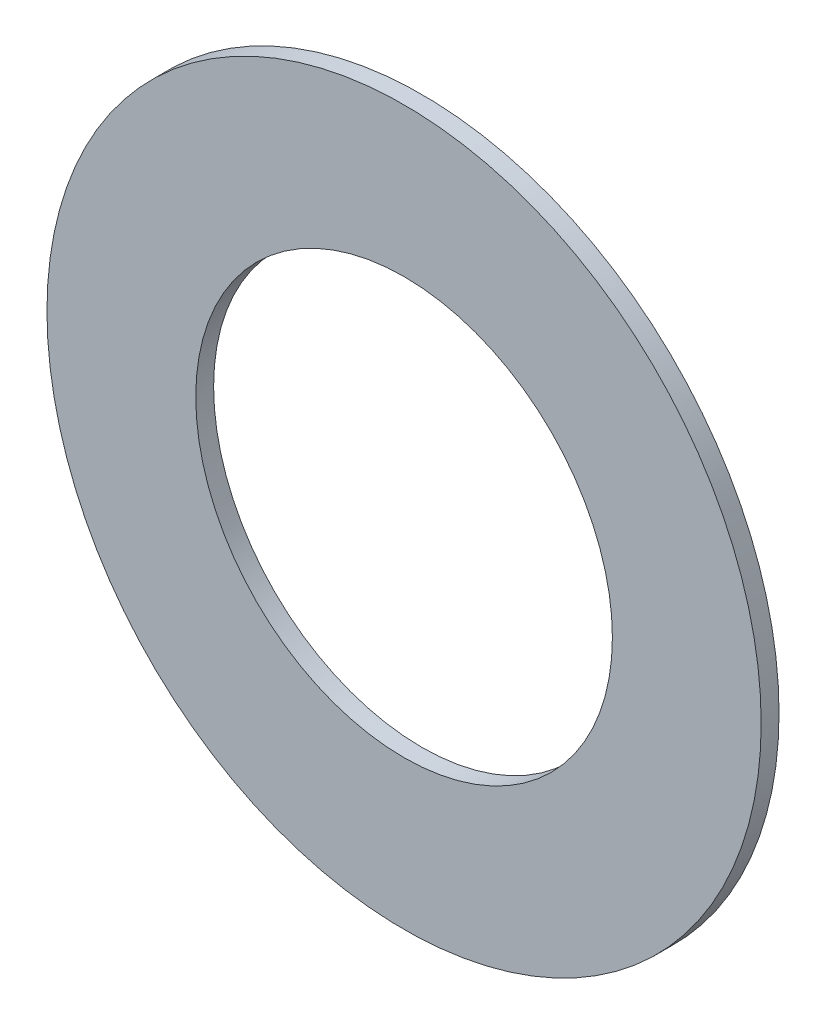
from build123d import *

# Parameters (mm, degrees)
CROQUIS1_R              = 6
CROQUIS1_R_2            = 3.5
SALIENTE_EXTRUIR1_DEPTH = 0.3


with BuildPart() as part:
    # Croquis1 → Saliente-Extruir1 (new body)
    with BuildSketch(Plane.XY):
        Circle(CROQUIS1_R)
        Circle(CROQUIS1_R_2, mode=Mode.SUBTRACT)
    extrude(amount=SALIENTE_EXTRUIR1_DEPTH)


solid = part.part
